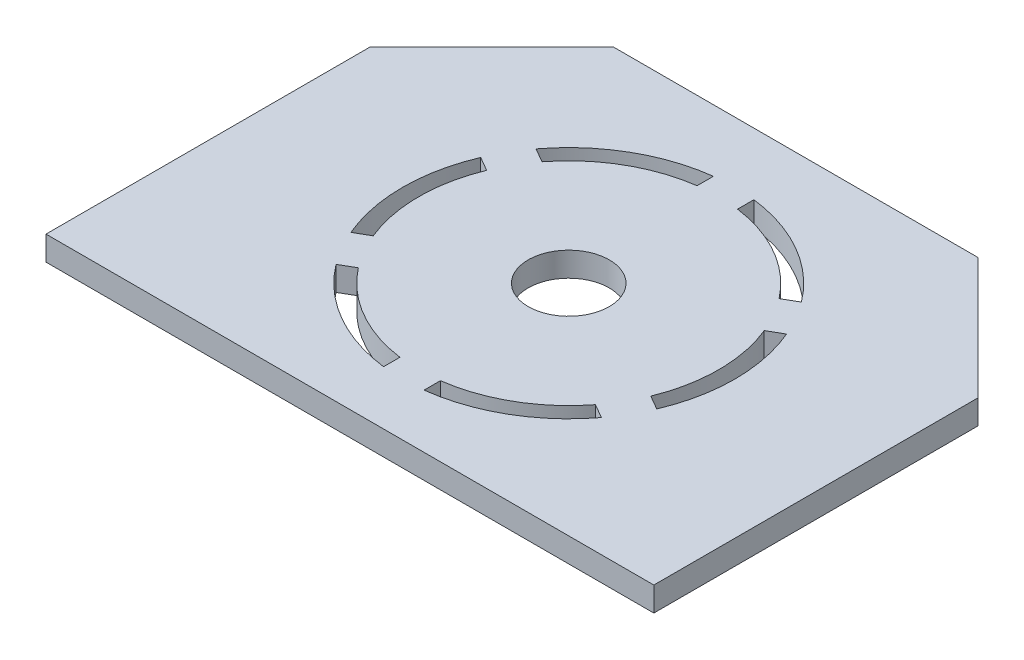
from build123d import *

# Parameters (mm, degrees)
SKETCH1_R             = 18.5
SKETCH1_R_2           = 5
BOSS_EXTRUDE1_DEPTH   = 3
SKETCH1_R_3           = 20.5
BOSS_EXTRUDE1_2_DEPTH = 3
BOSS_EXTRUDE2_DEPTH   = 3


with BuildPart() as part:
    # Sketch1 → Boss-Extrude1 (new body)
    with BuildSketch(Plane(origin=(0, 0, 0), x_dir=(1, 0, 0), z_dir=(0, 1, 0))):
        with Locations((20.568259386, 26.155290102)):
            Circle(SKETCH1_R)
        with Locations((20.568259386, 26.155290102)):
            Circle(SKETCH1_R_2, mode=Mode.SUBTRACT)
    extrude(amount=BOSS_EXTRUDE1_DEPTH)



with BuildPart() as body_2:
    # Sketch1 → Boss-Extrude1 2 (new body)
    with BuildSketch(Plane(origin=(0, 0, 0), x_dir=(1, 0, 0), z_dir=(0, 1, 0))):
        Polygon((-16.931740614, 39.155290102), (-1.931740614, 54.155290102), (43.068259386, 54.155290102), (58.068259386, 39.155290102), (58.068259386, -0.844709898), (-16.931740614, -0.844709898), align=None)
        with Locations((20.568259386, 26.155290102)):
            Circle(SKETCH1_R_3, mode=Mode.SUBTRACT)
    extrude(amount=BOSS_EXTRUDE1_2_DEPTH)


with BuildPart() as part_1:
    add(part.part)

    add(body_2.part)  # Boss-Extrude2 merges body 2
    # Sketch2 → Boss-Extrude2 (add, through all)
    with BuildSketch(Plane(origin=(0, 3, 0), x_dir=(1, 0, 0), z_dir=(0, 1, 0))):
        with BuildLine():
            Line((18.068259386, 44.485592882), (18.068259386, 46.502280052))
            ThreePointArc((18.068259386, 46.502280052), (20.568259386, 46.655290102), (23.068259386, 46.502280052))
            Line((23.068259386, 46.502280052), (23.068259386, 44.485592882))
            ThreePointArc((23.068259386, 44.485592882), (20.568259386, 44.655290102), (18.068259386, 44.485592882))
        make_face()
        with BuildLine():
            Line((35.192767252, 37.485505002), (36.939269572, 38.493848587))
            ThreePointArc((36.939269572, 38.493848587), (38.321780163, 36.405290102), (39.439269572, 34.163721568))
            Line((39.439269572, 34.163721568), (37.692767252, 33.155377983))
            ThreePointArc((37.692767252, 33.155377983), (36.589729356, 35.405290102), (35.192767252, 37.485505002))
        make_face()
        with BuildLine():
            Line((37.692767252, 19.155202222), (39.439269572, 18.146858637))
            ThreePointArc((39.439269572, 18.146858637), (38.321780163, 15.905290102), (36.939269572, 13.816731618))
            Line((36.939269572, 13.816731618), (35.192767252, 14.825075203))
            ThreePointArc((35.192767252, 14.825075203), (36.589729356, 16.905290102), (37.692767252, 19.155202222))
        make_face()
        with BuildLine():
            Line((23.068259386, 7.824987323), (23.068259386, 5.808300153))
            ThreePointArc((23.068259386, 5.808300153), (20.568259386, 5.655290102), (18.068259386, 5.808300153))
            Line((18.068259386, 5.808300153), (18.068259386, 7.824987323))
            ThreePointArc((18.068259386, 7.824987323), (20.568259386, 7.655290102), (23.068259386, 7.824987323))
        make_face()
        with BuildLine():
            Line((5.943751519, 14.825075203), (4.197249199, 13.816731618))
            ThreePointArc((4.197249199, 13.816731618), (2.814738608, 15.905290102), (1.697249199, 18.146858637))
            Line((1.697249199, 18.146858637), (3.443751519, 19.155202222))
            ThreePointArc((3.443751519, 19.155202222), (4.546789416, 16.905290102), (5.943751519, 14.825075203))
        make_face()
        with BuildLine():
            Line((3.443751519, 33.155377983), (1.697249199, 34.163721568))
            ThreePointArc((1.697249199, 34.163721568), (2.814738608, 36.405290102), (4.197249199, 38.493848587))
            Line((4.197249199, 38.493848587), (5.943751519, 37.485505002))
            ThreePointArc((5.943751519, 37.485505002), (4.546789416, 35.405290102), (3.443751519, 33.155377983))
        make_face()
    extrude(amount=-BOSS_EXTRUDE2_DEPTH)


solid = part_1.part
